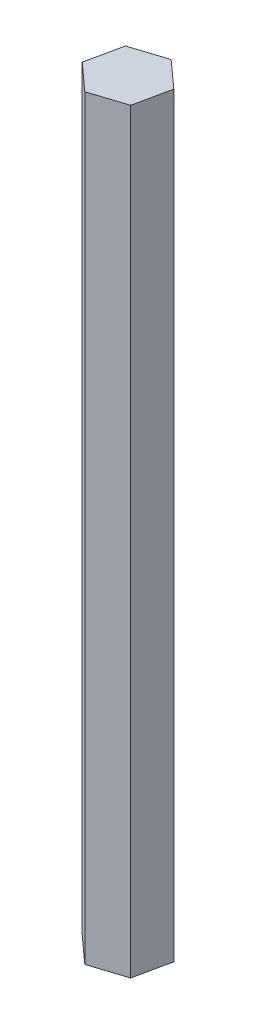
from build123d import *

# Parameters (mm, degrees)
BOSS_EXTRUDE1_DEPTH = 152.4


with BuildPart() as part:
    # Sketch1 → Boss-Extrude1 (new body)
    with BuildSketch(Plane(origin=(0, 0, 0), x_dir=(1, 0, 0), z_dir=(0, 1, 0))):
        Polygon((2.083575367, -0.365699732), (3.622703428, 6.803290305), (-1.816260032, 11.720709324), (-8.794351554, 9.469138307), (-10.333479615, 2.30014827), (-4.894516155, -2.617270749), align=None)
    extrude(amount=BOSS_EXTRUDE1_DEPTH)


solid = part.part
